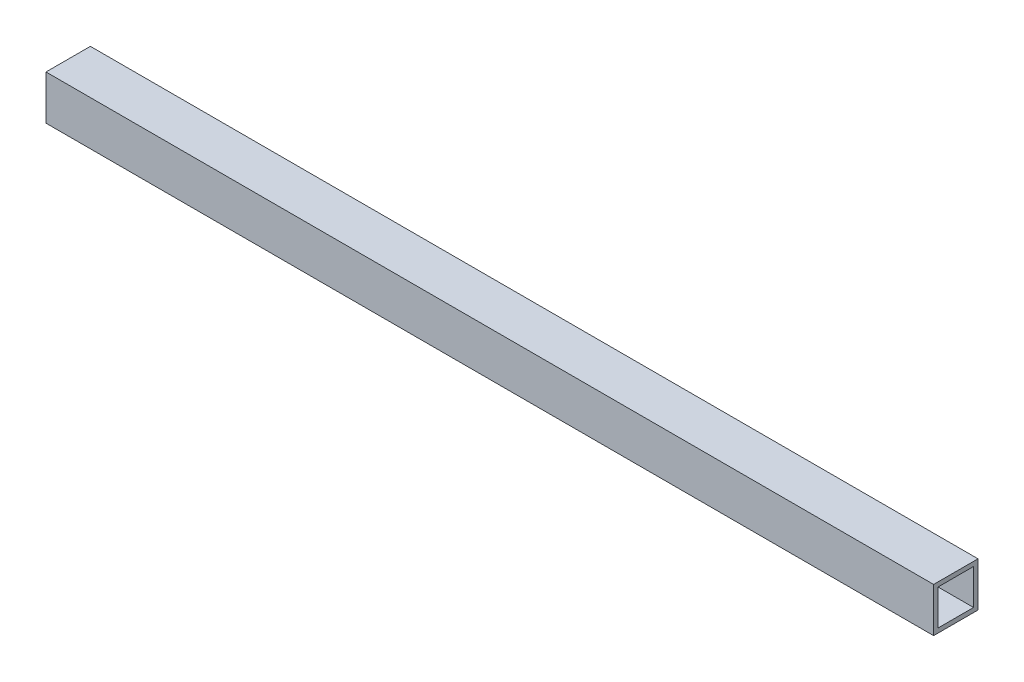
from build123d import *

# Parameters (mm, degrees)
SKETCH1_W           = 15
SKETCH1_H           = 15
SKETCH1_W_2         = 12
SKETCH1_H_2         = 12
BOSS_EXTRUDE1_DEPTH = 300


with BuildPart() as part:
    # Sketch1 → Boss-Extrude1 (new body)
    with BuildSketch(Plane(origin=(0, 0, 0), x_dir=(0, 0, -1), z_dir=(1, 0, 0))):
        Rectangle(SKETCH1_W, SKETCH1_H)
        Rectangle(SKETCH1_W_2, SKETCH1_H_2, mode=Mode.SUBTRACT)
    extrude(amount=BOSS_EXTRUDE1_DEPTH)


solid = part.part
